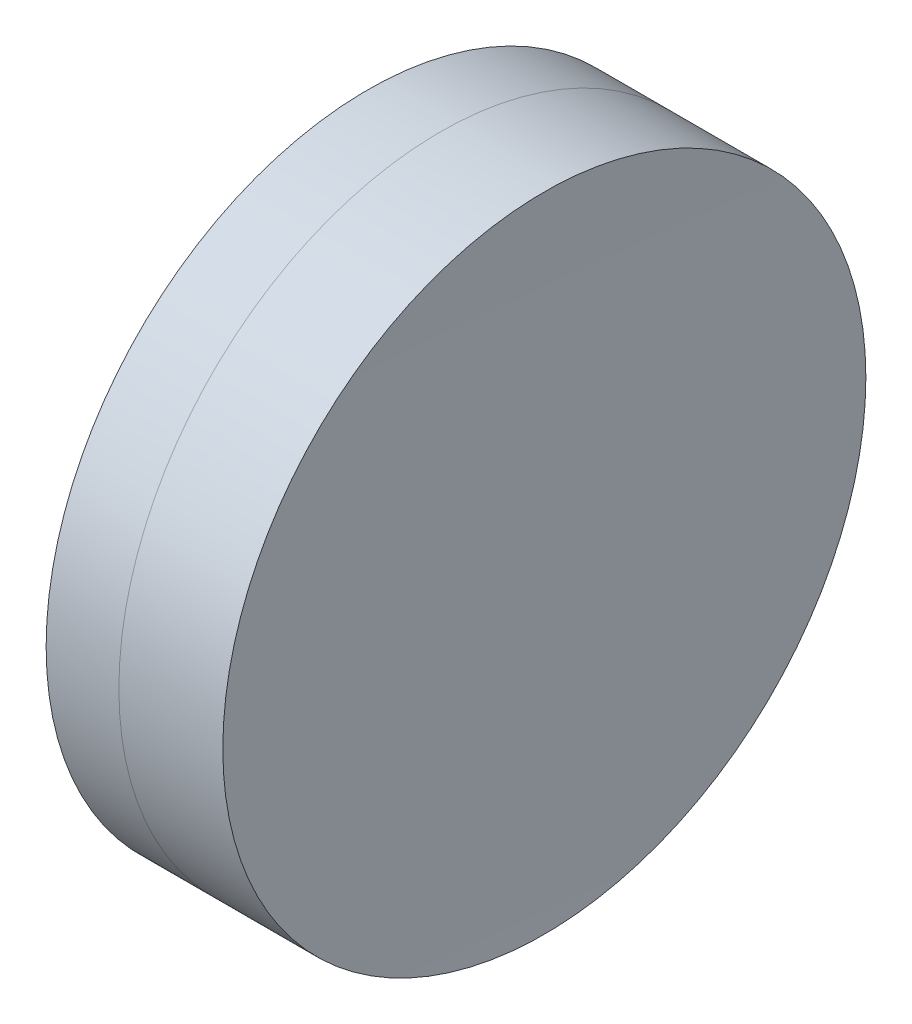
from build123d import *


with BuildPart() as part:
    # 草图1 one side → 旋转1 (revolve)
    with BuildSketch(Plane(origin=(0, 0, 0), x_dir=(1, 0, 0), z_dir=(0, 1, 0)), mode=Mode.PRIVATE) as revolve_1_sk:
        with BuildLine():
            ThreePointArc((299.170248761, 6.35), (298.749552707, 3.187379364), (298.60895665, 0))
            Line((298.60895665, 0), (301.10895665, 0))
            ThreePointArc((301.10895665, 0), (300.983220559, 3.184912337), (300.606794938, 6.35))
            Line((300.606794938, 6.35), (299.170248761, 6.35))
        make_face()
    revolve(revolve_1_sk.sketch.rotate(Axis((124.523309526, 0, 0), (1, 0, 0)), 180), axis=Axis((124.523309526, 0, 0), (1, 0, 0)))  # turned: the seam where the file's is


with BuildPart() as body_2:
    # 草图2 one side → 旋转3 (revolve)
    with BuildSketch(Plane(origin=(0, 0, 0), x_dir=(1, 0, 0), z_dir=(0, 1, 0)), mode=Mode.PRIVATE) as revolve_3_sk:
        with BuildLine():
            Line((302.659603555, 6.35), (300.606794938, 6.35))
            ThreePointArc((300.606794938, 6.35), (300.983220559, 3.184912337), (301.10895665, 0))
            Line((301.10895665, 0), (302.60895665, 0))
            ThreePointArc((302.60895665, 0), (302.621618578, 3.175100987), (302.659603555, 6.35))
        make_face()
    revolve(revolve_3_sk.sketch.rotate(Axis((-0.551919993, 0, 0), (1, 0, 0)), 180), axis=Axis((-0.551919993, 0, 0), (1, 0, 0)))  # turned: the seam where the file's is


solid = Compound([part.part, body_2.part])
